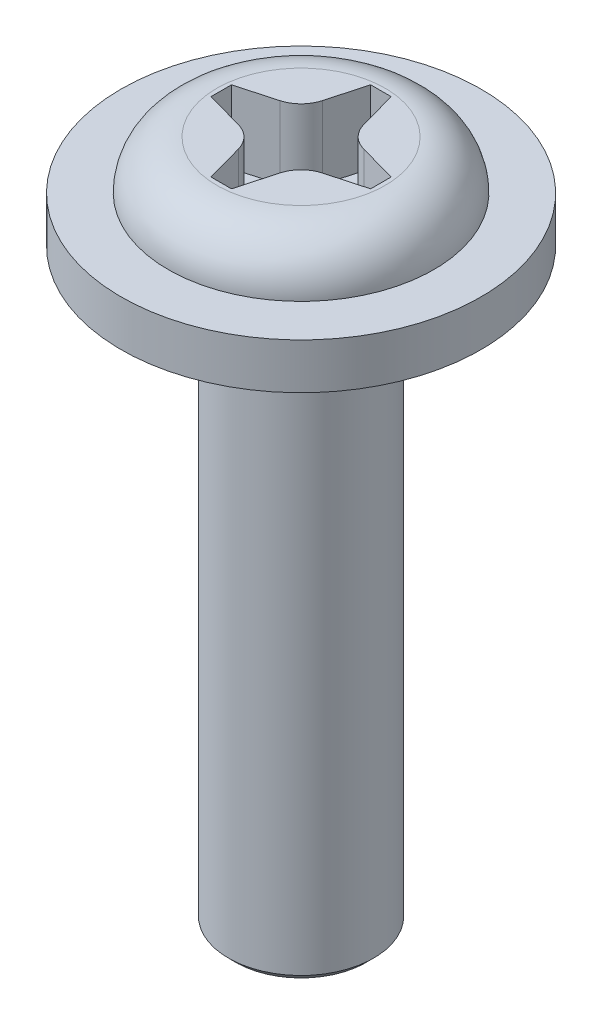
from build123d import *

# Parameters (mm, degrees)
CUT_EXTRUDE1_DEPTH = 1


with BuildPart() as part:
    # Sketch1 → Revolve1 (revolve)
    with BuildSketch(Plane.XY):
        with BuildLine():
            Line((0, -9.4), (0.9, -9.4))
            Line((0.9, -9.4), (1, -9.3))
            Line((1, -9.3), (1, -1.3))
            Line((1, -1.3), (2.48, -1.3))
            Line((2.48, -1.3), (2.48, -0.67))
            Line((2.48, -0.67), (1.83, -0.67))
            ThreePointArc((1.83, -0.67), (1.633761543, -0.196238457), (1.16, 0))
            Line((1.16, 0), (0, 0))
            Line((0, 0), (0, -9.4))
        make_face()
    revolve(axis=Axis((0, 0, 0), (0, -1, 0)))

    # Sketch2 → Cut-Extrude1 (cut)
    with BuildSketch(Plane(origin=(0, 0, 0), x_dir=(1, 0, 0), z_dir=(0, 1, 0))):
        with BuildLine():
            Line((0, 1.1), (0.141406897, 1.1))
            Line((0.141406897, 1.1), (0.285471459, 0.578570854))
            ThreePointArc((0.285471459, 0.578570854), (0.393362387, 0.393362387), (0.578570854, 0.285471459))
            Line((0.578570854, 0.285471459), (1.1, 0.141406897))
            Line((1.1, 0.141406897), (1.1, 0))
            Line((1.1, 0), (1.1, -0.141406897))
            Line((1.1, -0.141406897), (0.578570854, -0.285471459))
            ThreePointArc((0.578570854, -0.285471459), (0.393362387, -0.393362387), (0.285471459, -0.578570854))
            Line((0.285471459, -0.578570854), (0.141406897, -1.1))
            Line((0.141406897, -1.1), (0, -1.1))
            Line((0, -1.1), (-0.141406897, -1.1))
            Line((-0.141406897, -1.1), (-0.285471459, -0.578570854))
            ThreePointArc((-0.285471459, -0.578570854), (-0.393362387, -0.393362387), (-0.578570854, -0.285471459))
            Line((-0.578570854, -0.285471459), (-1.1, -0.141406897))
            Line((-1.1, -0.141406897), (-1.1, 0))
            Line((-1.1, 0), (-1.1, 0.141406897))
            Line((-1.1, 0.141406897), (-0.578570854, 0.285471459))
            ThreePointArc((-0.578570854, 0.285471459), (-0.393362387, 0.393362387), (-0.285471459, 0.578570854))
            Line((-0.285471459, 0.578570854), (-0.141406897, 1.1))
            Line((-0.141406897, 1.1), (0, 1.1))
        make_face()
    extrude(amount=-CUT_EXTRUDE1_DEPTH, mode=Mode.SUBTRACT)


solid = part.part
